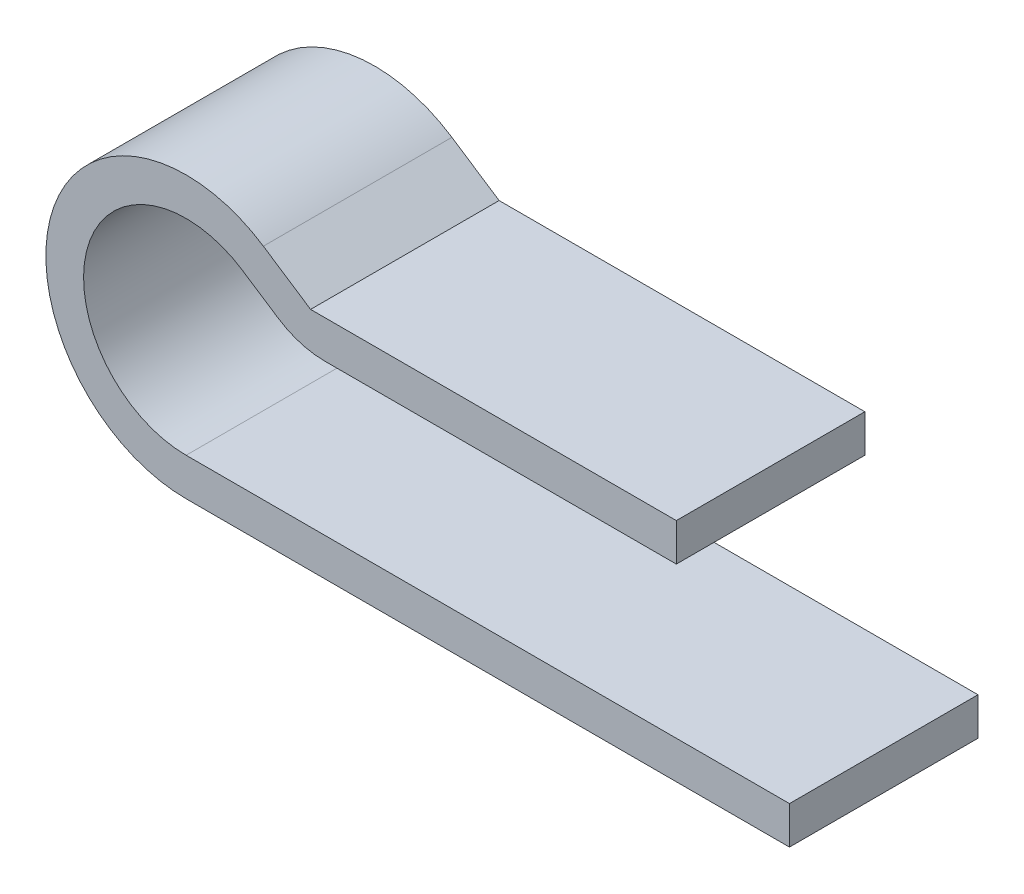
from build123d import *

# Parameters (mm, degrees)
BOSS_EXTRUDE1_DEPTH = 1
FILLET2_R           = 0.45


with BuildPart() as part:
    # Sketch1 → Boss-Extrude1 (new body)
    with BuildSketch(Plane.XY):
        with BuildLine():
            Line((-1.6, 0), (1.6, 0))
            Line((1.6, 0), (1.6, -0.2))
            Line((1.6, -0.2), (-1.6, -0.2))
            ThreePointArc((-1.6, -0.2), (-2.312622756, 0.757786827), (-1.190458716, 1.165137615))
            Line((-1.190458716, 1.165137615), (-0.94, 1))
            Line((-0.94, 1), (1, 1))
            Line((1, 1), (1, 0.8))
            Line((1, 0.8), (-1, 0.8))
            Line((-1, 0.8), (-1.300550459, 0.998165138))
            ThreePointArc((-1.300550459, 0.998165138), (-2.121057499, 0.70031725), (-1.6, 0))
        make_face()
    extrude(amount=BOSS_EXTRUDE1_DEPTH)

    # Fillet2
    fillet2_edges = [part.edges().sort_by_distance(p)[0] for p in [
        (-1, 0.8, 0.5),
    ]]
    fillet(fillet2_edges, radius=FILLET2_R)


solid = part.part
